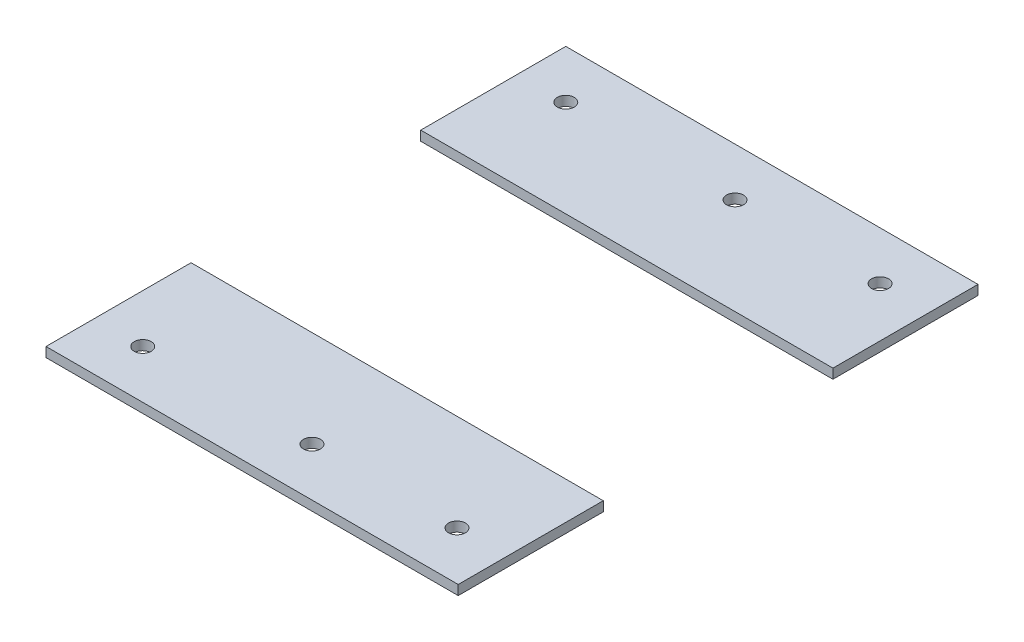
from build123d import *

# Parameters (mm, degrees)
SKETCH1_W           = 170.5
SKETCH1_H           = 215
SKETCH1_R           = 3.5
BOSS_EXTRUDE1_DEPTH = 4
SKETCH2_W           = 219.467368697
SKETCH2_H           = 95
CUT_EXTRUDE1_DEPTH  = 10


with BuildPart() as part:
    # Sketch1 → Boss-Extrude1 (new body)
    with BuildSketch(Plane(origin=(0, 0, 0), x_dir=(1, 0, 0), z_dir=(0, 1, 0))):
        with Locations((85.25, 97.5)):
            Rectangle(SKETCH1_W, SKETCH1_H)
        with Locations((20, 10)):
            Circle(SKETCH1_R, mode=Mode.SUBTRACT)
        with Locations((150, 10)):
            Circle(SKETCH1_R, mode=Mode.SUBTRACT)
        with Locations((90, 10)):
            Circle(SKETCH1_R, mode=Mode.SUBTRACT)
        with Locations((20, 185)):
            Circle(SKETCH1_R, mode=Mode.SUBTRACT)
        with Locations((90, 185)):
            Circle(SKETCH1_R, mode=Mode.SUBTRACT)
        with Locations((150, 185)):
            Circle(SKETCH1_R, mode=Mode.SUBTRACT)
    extrude(amount=BOSS_EXTRUDE1_DEPTH)

    # Sketch2 → Cut-Extrude1 (cut)
    with BuildSketch(Plane.XZ):
        with Locations((84.733684349, -97.5)):
            Rectangle(SKETCH2_W, SKETCH2_H)
    extrude(amount=-CUT_EXTRUDE1_DEPTH, mode=Mode.SUBTRACT)


solid = part.part
